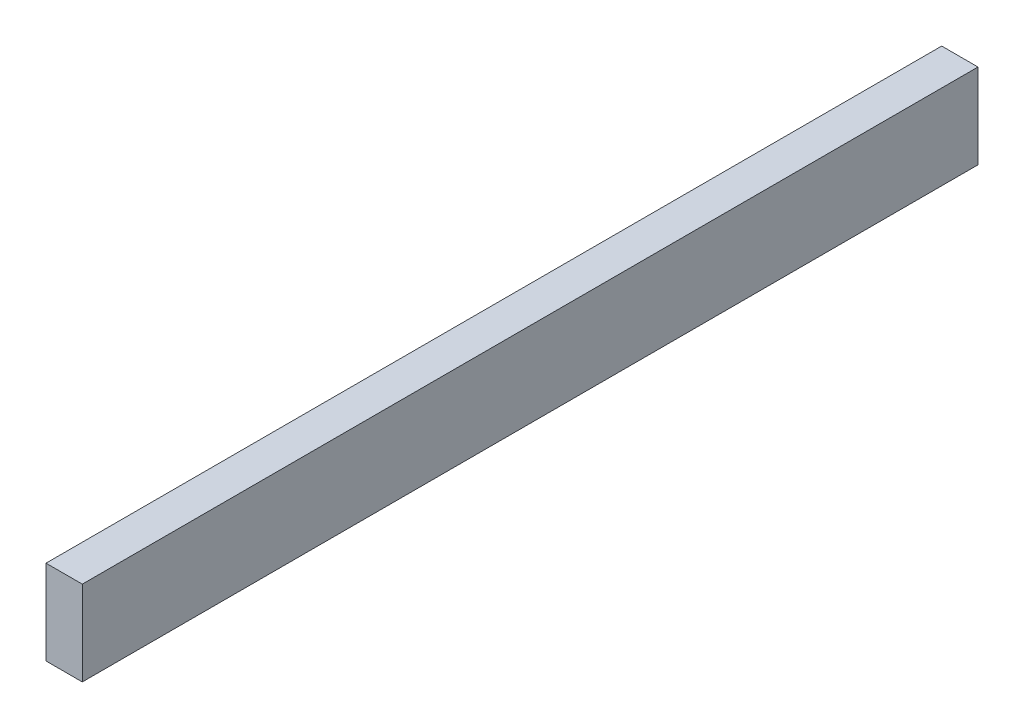
from build123d import *

# Parameters (mm, degrees)
SKETCH1_W           = 38.1
SKETCH1_H           = 88.9
BOSS_EXTRUDE1_DEPTH = 939.8


with BuildPart() as part:
    # Sketch1 → Boss-Extrude1 (new body)
    with BuildSketch(Plane.XY):
        with Locations((-19.05, 20.011487482)):
            Rectangle(SKETCH1_W, SKETCH1_H)
    extrude(amount=BOSS_EXTRUDE1_DEPTH)


solid = part.part
